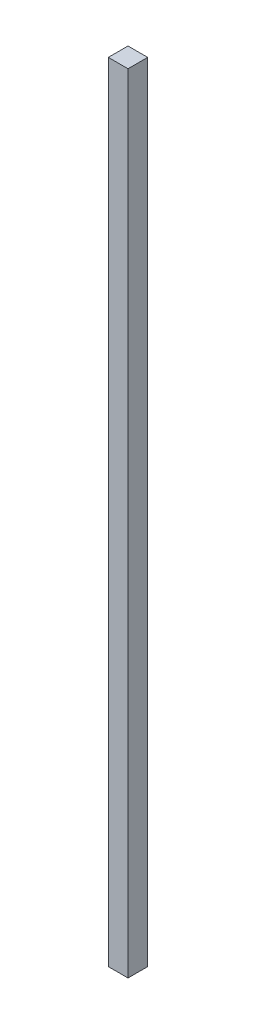
from build123d import *

# Parameters (mm, degrees)
SKETCH1_W           = 2
SKETCH1_H           = 2
BOSS_EXTRUDE1_DEPTH = 80


with BuildPart() as part:
    # Sketch1 → Boss-Extrude1 (new body)
    with BuildSketch(Plane(origin=(0, 0, 0), x_dir=(1, 0, 0), z_dir=(0, 1, 0))):
        Rectangle(SKETCH1_W, SKETCH1_H)
    extrude(amount=BOSS_EXTRUDE1_DEPTH)


solid = part.part
